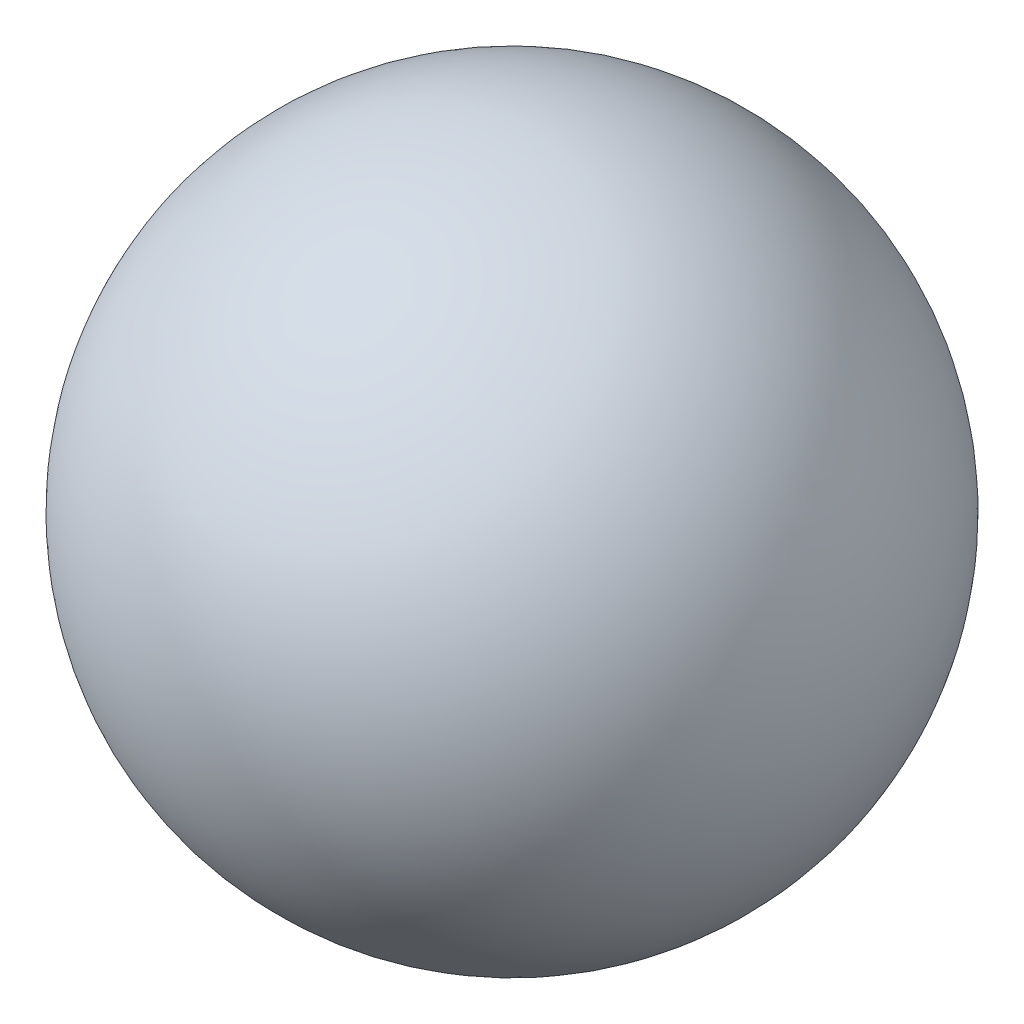
from build123d import *


with BuildPart() as part:
    # Sketch1 → Revolve5 (revolve)
    with BuildSketch(Plane(origin=(0, 0, 0), x_dir=(1, 0, 0), z_dir=(0, 1, 0))):
        with BuildLine():
            Line((-6.35, 0), (6.35, 0))
            ThreePointArc((6.35, 0), (0, 6.35), (-6.35, 0))
        make_face()
    revolve(axis=Axis((-8.843195093, 0, 0), (1, 0, 0)))


solid = part.part
